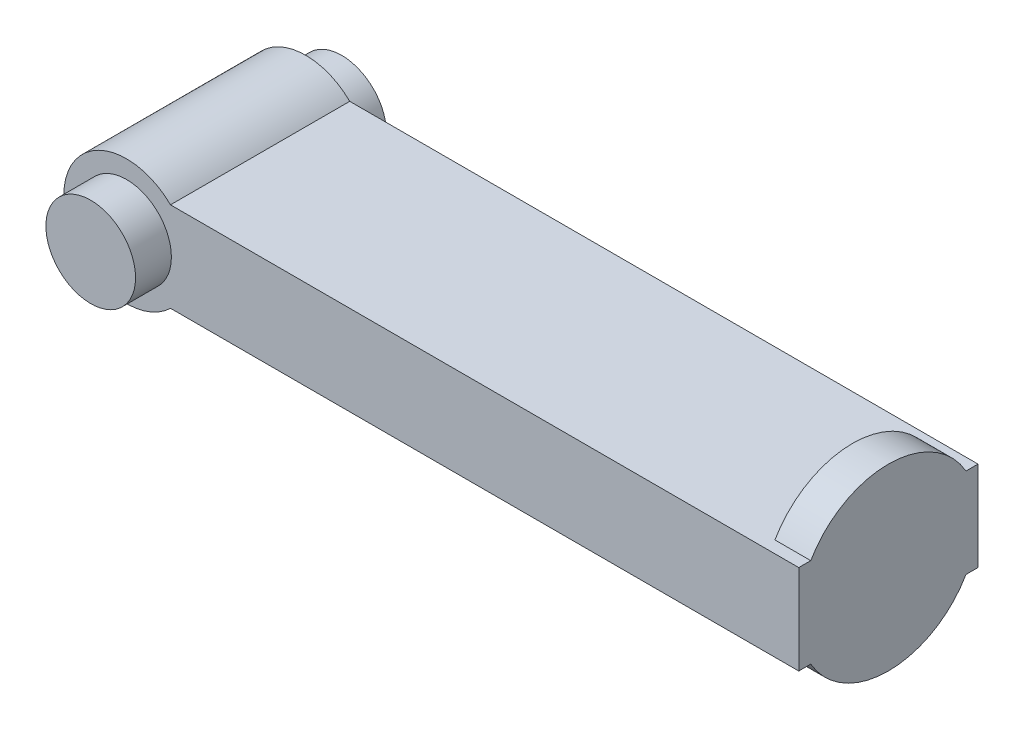
from build123d import *

# Parameters (mm, degrees)
BOSS_EXTRUDE1_DEPTH      = 100
SKETCH2_R                = 50
BOSS_EXTRUDE2_DEPTH      = 20
SKETCH3_R                = 25
BOSS_EXTRUDE3_DEPTH      = 20
BOSS_EXTRUDE3_DEPTH_BACK = 120


with BuildPart() as part:
    # Sketch1 → Boss-Extrude1 (new body)
    with BuildSketch(Plane.XY):
        with BuildLine():
            Line((24.494897428, 25), (375, 25))
            Line((375, 25), (375, -25))
            Line((375, -25), (24.494897428, -25))
            ThreePointArc((24.494897428, -25), (-35, 0), (24.494897428, 25))
        make_face()
    extrude(amount=BOSS_EXTRUDE1_DEPTH)

    # Sketch2 → Boss-Extrude2 (add)
    with BuildSketch(Plane(origin=(375, 0, 0), x_dir=(0, 0, -1), z_dir=(1, 0, 0))):
        with Locations((-50, 0)):
            Circle(SKETCH2_R)
    extrude(amount=-BOSS_EXTRUDE2_DEPTH)

    # Sketch3 → Boss-Extrude3 (add, two sides)
    with BuildSketch(Plane.XY.offset(100)) as boss_extrude3_sk:
        Circle(SKETCH3_R)
    extrude(amount=BOSS_EXTRUDE3_DEPTH)
    extrude(boss_extrude3_sk.sketch, amount=-BOSS_EXTRUDE3_DEPTH_BACK)


solid = part.part
